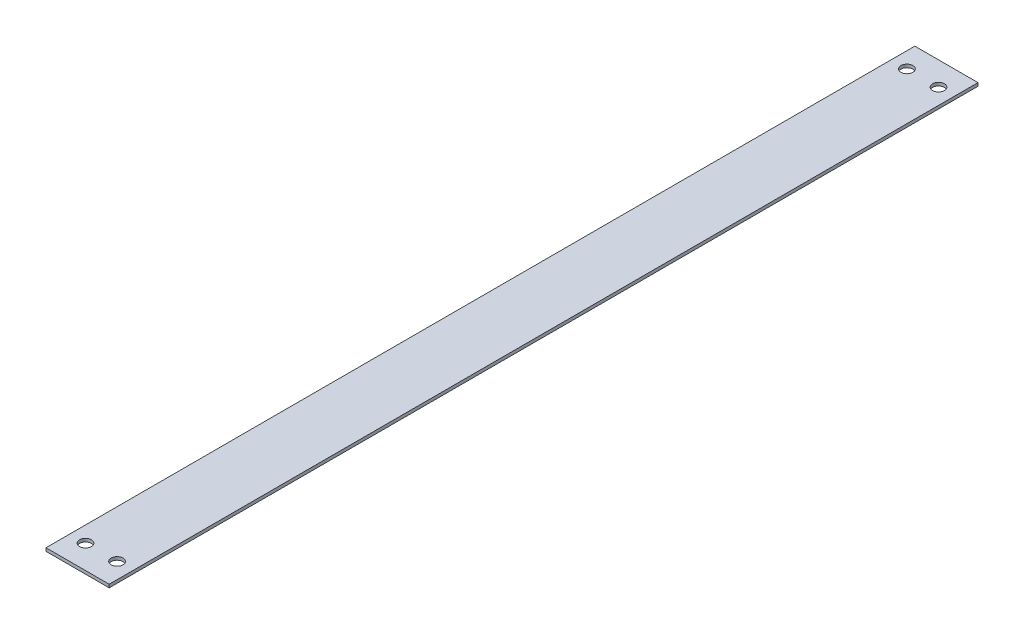
from build123d import *

# Parameters (mm, degrees)
SKETCH1_W               = 50.8
SKETCH1_H               = 698.5
BOSS_EXTRUDE1_DEPTH     = 2.54
SKETCH2_R               = 4.7625
CUT_EXTRUDE1_DEPTH      = 1
CUT_EXTRUDE1_DEPTH_BACK = 3.54


with BuildPart() as part:
    # Sketch1 → Boss-Extrude1 (new body)
    with BuildSketch(Plane(origin=(0, 0, 0), x_dir=(1, 0, 0), z_dir=(0, 1, 0))):
        Rectangle(SKETCH1_W, SKETCH1_H)
    extrude(amount=BOSS_EXTRUDE1_DEPTH)

    # Sketch2 → Cut-Extrude1 (cut, two sides)
    with BuildSketch(Plane(origin=(0, 2.54, 0), x_dir=(1, 0, 0), z_dir=(0, 1, 0))) as cut_extrude1_sk:
        with Locations((-12.7, 330.2)):
            Circle(SKETCH2_R)
        with Locations((12.7, 330.2)):
            Circle(SKETCH2_R)
        with Locations((12.7, -330.2)):
            Circle(SKETCH2_R)
        with Locations((-12.7, -330.2)):
            Circle(SKETCH2_R)
    extrude(amount=CUT_EXTRUDE1_DEPTH, mode=Mode.SUBTRACT)
    extrude(cut_extrude1_sk.sketch, amount=-CUT_EXTRUDE1_DEPTH_BACK, mode=Mode.SUBTRACT)


solid = part.part
